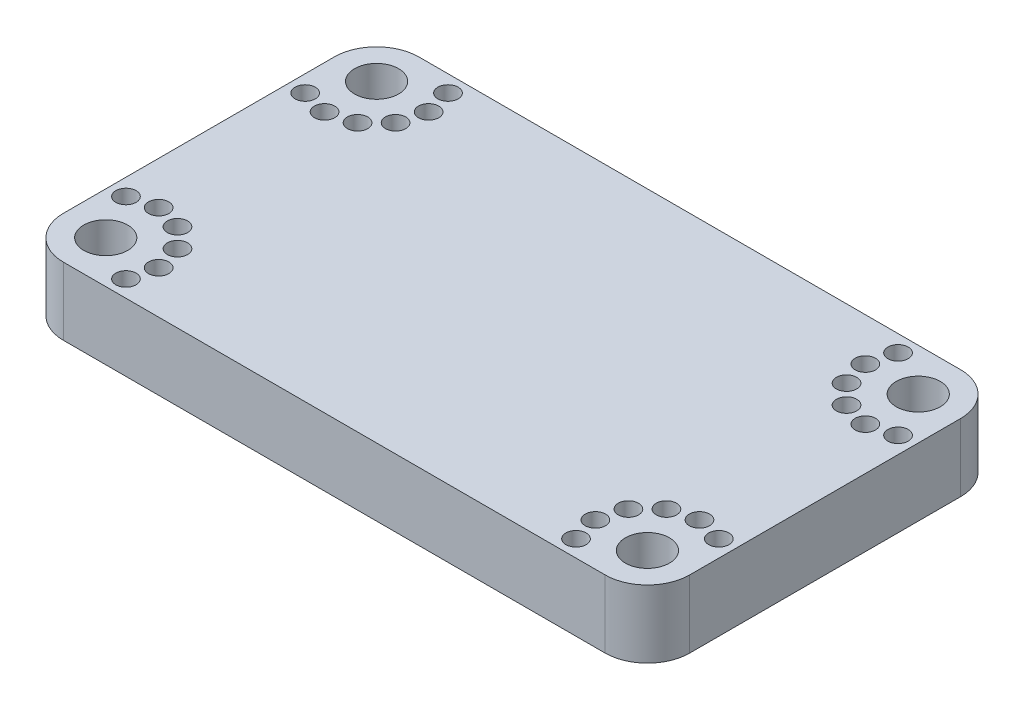
from build123d import *

# Parameters (mm, degrees)
SKETCH1_R           = 3.25
SKETCH1_R_2         = 1.5
BOSS_EXTRUDE1_DEPTH = 10


with BuildPart() as part:
    # Sketch1 → Boss-Extrude1 (new body)
    with BuildSketch(Plane(origin=(0, 0, 0), x_dir=(1, 0, 0), z_dir=(0, 1, 0))):
        with BuildLine():
            Line((-40, -26.25), (40, -26.25))
            ThreePointArc((40, -26.25), (44.419417382, -24.419417382), (46.25, -20))
            Line((46.25, -20), (46.25, 20))
            ThreePointArc((46.25, 20), (44.419417382, 24.419417382), (40, 26.25))
            Line((40, 26.25), (-40, 26.25))
            ThreePointArc((-40, 26.25), (-44.419417382, 24.419417382), (-46.25, 20))
            Line((-46.25, 20), (-46.25, -20))
            ThreePointArc((-46.25, -20), (-44.419417382, -24.419417382), (-40, -26.25))
        make_face()
        with Locations((-40, 20)):
            Circle(SKETCH1_R, mode=Mode.SUBTRACT)
        with Locations((-40, -20)):
            Circle(SKETCH1_R, mode=Mode.SUBTRACT)
        with Locations((40, -20)):
            Circle(SKETCH1_R, mode=Mode.SUBTRACT)
        with Locations((40, 20)):
            Circle(SKETCH1_R, mode=Mode.SUBTRACT)
        with Locations((-43.78036994, 13.234550782)):
            Circle(SKETCH1_R_2, mode=Mode.SUBTRACT)
        with Locations((-39.934701703, 12.250275093)):
            Circle(SKETCH1_R_2, mode=Mode.SUBTRACT)
        with Locations((-36.10616509, 13.299212756)):
            Circle(SKETCH1_R_2, mode=Mode.SUBTRACT)
        with Locations((-33.299212756, 16.10616509)):
            Circle(SKETCH1_R_2, mode=Mode.SUBTRACT)
        with Locations((-32.250275093, 19.934701703)):
            Circle(SKETCH1_R_2, mode=Mode.SUBTRACT)
        with Locations((-33.234550782, 23.78036994)):
            Circle(SKETCH1_R_2, mode=Mode.SUBTRACT)
        with Locations((-33.234550782, -23.78036994)):
            Circle(SKETCH1_R_2, mode=Mode.SUBTRACT)
        with Locations((-32.250275093, -19.934701703)):
            Circle(SKETCH1_R_2, mode=Mode.SUBTRACT)
        with Locations((-33.299212756, -16.10616509)):
            Circle(SKETCH1_R_2, mode=Mode.SUBTRACT)
        with Locations((-36.10616509, -13.299212756)):
            Circle(SKETCH1_R_2, mode=Mode.SUBTRACT)
        with Locations((-39.934701703, -12.250275093)):
            Circle(SKETCH1_R_2, mode=Mode.SUBTRACT)
        with Locations((-43.78036994, -13.234550782)):
            Circle(SKETCH1_R_2, mode=Mode.SUBTRACT)
        with Locations((33.234550782, 23.78036994)):
            Circle(SKETCH1_R_2, mode=Mode.SUBTRACT)
        with Locations((32.250275093, 19.934701703)):
            Circle(SKETCH1_R_2, mode=Mode.SUBTRACT)
        with Locations((33.299212756, 16.10616509)):
            Circle(SKETCH1_R_2, mode=Mode.SUBTRACT)
        with Locations((39.934701703, 12.250275093)):
            Circle(SKETCH1_R_2, mode=Mode.SUBTRACT)
        with Locations((43.78036994, 13.234550782)):
            Circle(SKETCH1_R_2, mode=Mode.SUBTRACT)
        with Locations((36.10616509, 13.299212756)):
            Circle(SKETCH1_R_2, mode=Mode.SUBTRACT)
        with Locations((33.234550782, -23.78036994)):
            Circle(SKETCH1_R_2, mode=Mode.SUBTRACT)
        with Locations((32.250275093, -19.934701703)):
            Circle(SKETCH1_R_2, mode=Mode.SUBTRACT)
        with Locations((33.299212756, -16.10616509)):
            Circle(SKETCH1_R_2, mode=Mode.SUBTRACT)
        with Locations((36.10616509, -13.299212756)):
            Circle(SKETCH1_R_2, mode=Mode.SUBTRACT)
        with Locations((39.934701703, -12.250275093)):
            Circle(SKETCH1_R_2, mode=Mode.SUBTRACT)
        with Locations((43.78036994, -13.234550782)):
            Circle(SKETCH1_R_2, mode=Mode.SUBTRACT)
    extrude(amount=BOSS_EXTRUDE1_DEPTH)


solid = part.part
